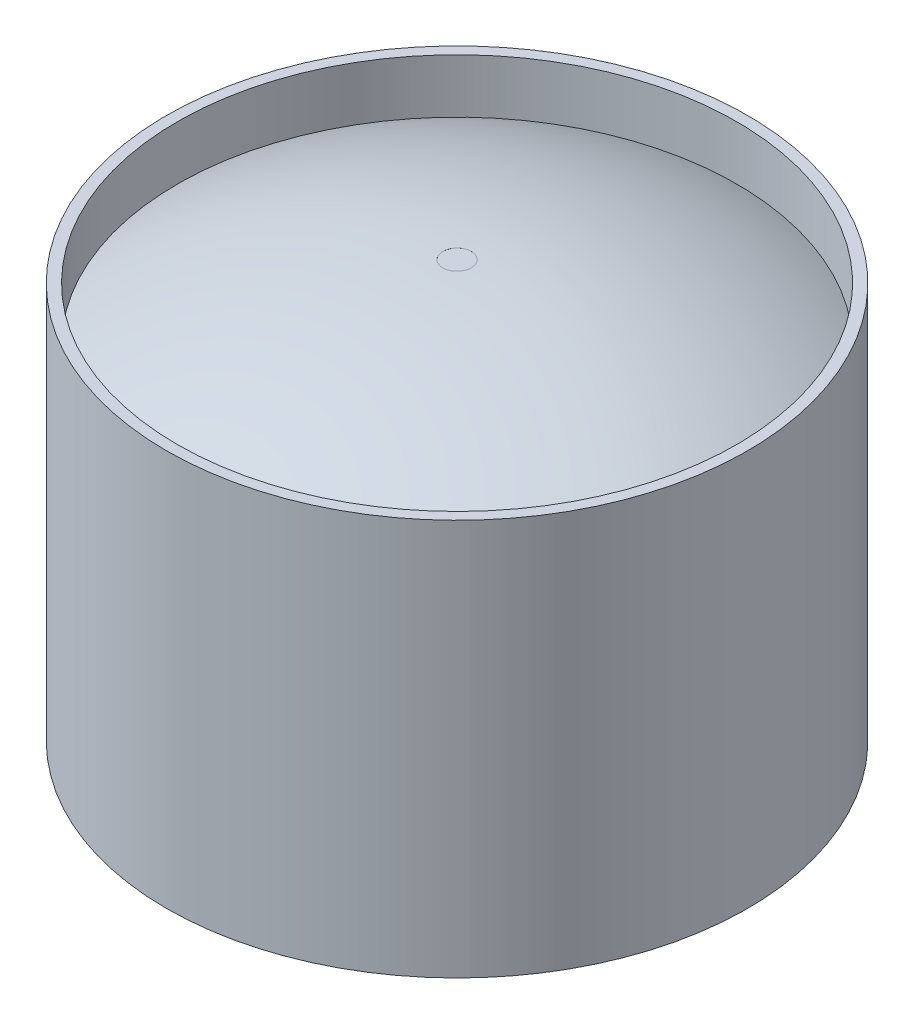
from build123d import *

# Parameters (mm, degrees)
SKETCH1_R                = 4.03065
SKETCH1_R_2              = 3.88065
BOSS_EXTRUDE1_DEPTH      = 5.5
SKETCH3_R                = 0.197408615
BOSS_EXTRUDE2_DEPTH      = 0.28159739
BOSS_EXTRUDE2_DEPTH_BACK = 5.5


with BuildPart() as part:
    # Sketch1 → Boss-Extrude1 (new body)
    with BuildSketch(Plane(origin=(0, 0, 0), x_dir=(1, 0, 0), z_dir=(0, 1, 0))):
        Circle(SKETCH1_R)
        Circle(SKETCH1_R_2, mode=Mode.SUBTRACT)
    extrude(amount=BOSS_EXTRUDE1_DEPTH)

    # Sketch2 → Revolve1 (revolve)
    with BuildSketch(Plane.XY):
        with BuildLine():
            Line((0.197408615, 0), (0.197408615, 5.781917471))
            ThreePointArc((0.197408615, 5.781917471), (2.106547816, 5.506953748), (3.88065, 4.75))
            Line((3.88065, 4.75), (3.88065, 0.75))
            ThreePointArc((3.88065, 0.75), (2.068627273, 0.229644733), (0.197408615, 0))
        make_face()
    revolve(axis=Axis((0, 5.5, 0), (0, -1, 0)))

    # Sketch3 → Boss-Extrude2 (add, two sides)
    with BuildSketch(Plane(origin=(0, 5.5, 0), x_dir=(1, 0, 0), z_dir=(0, 1, 0))) as boss_extrude2_sk:
        Circle(SKETCH3_R)
    extrude(amount=BOSS_EXTRUDE2_DEPTH)
    extrude(boss_extrude2_sk.sketch, amount=-BOSS_EXTRUDE2_DEPTH_BACK)


solid = part.part
